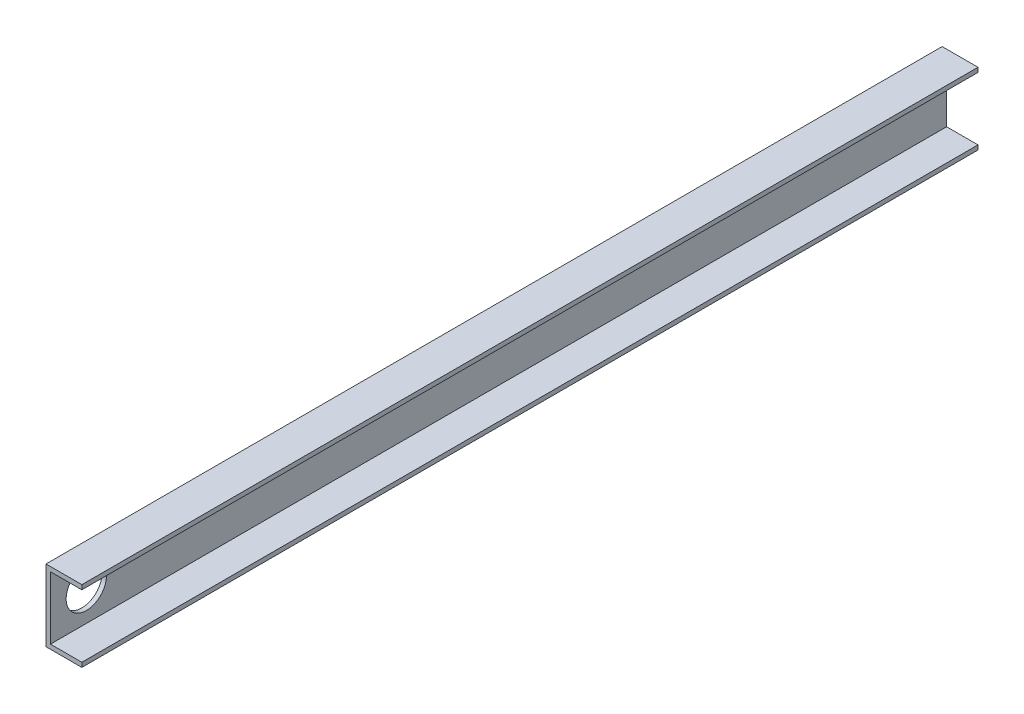
from build123d import *

# Parameters (mm, degrees)
BOSS_EXTRUDE1_DEPTH = 635
SKETCH2_R           = 14.2875
CUT_EXTRUDE1_DEPTH  = 26.4


with BuildPart() as part:
    # Sketch1 → Boss-Extrude1 (new body)
    with BuildSketch(Plane.XY):
        Polygon((0, 0), (0, 50.8), (25.4, 50.8), (25.4, 47.625), (3.175, 47.625), (3.175, 3.175), (25.4, 3.175), (25.4, 0), align=None)
    extrude(amount=BOSS_EXTRUDE1_DEPTH)

    # Sketch2 → Cut-Extrude1 (cut, through all)
    with BuildSketch(Plane.ZY):
        with Locations((609.6, 25.4)):
            Circle(SKETCH2_R)
    extrude(amount=-CUT_EXTRUDE1_DEPTH, mode=Mode.SUBTRACT)


solid = part.part
